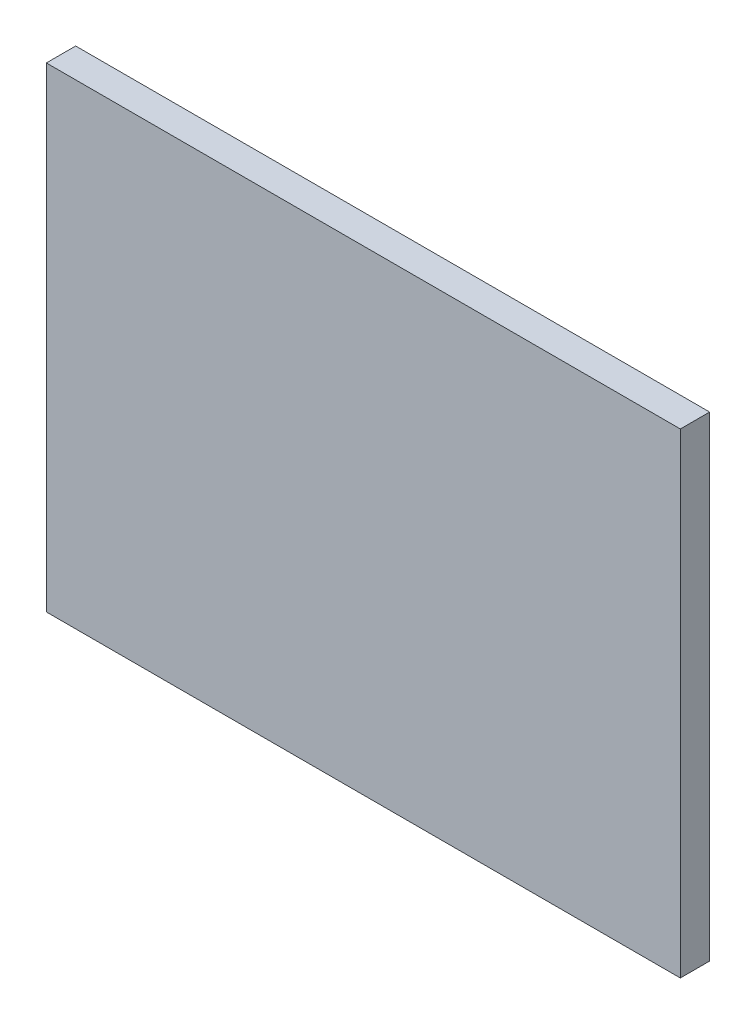
from build123d import *

# Parameters (mm, degrees)
SKETCH1_W           = 203.2
SKETCH1_H           = 152.4
BOSS_EXTRUDE1_DEPTH = 9.398


with BuildPart() as part:
    # Sketch1 → Boss-Extrude1 (new body)
    with BuildSketch(Plane.XY):
        with Locations((101.6, 76.2)):
            Rectangle(SKETCH1_W, SKETCH1_H)
    extrude(amount=BOSS_EXTRUDE1_DEPTH)


solid = part.part
